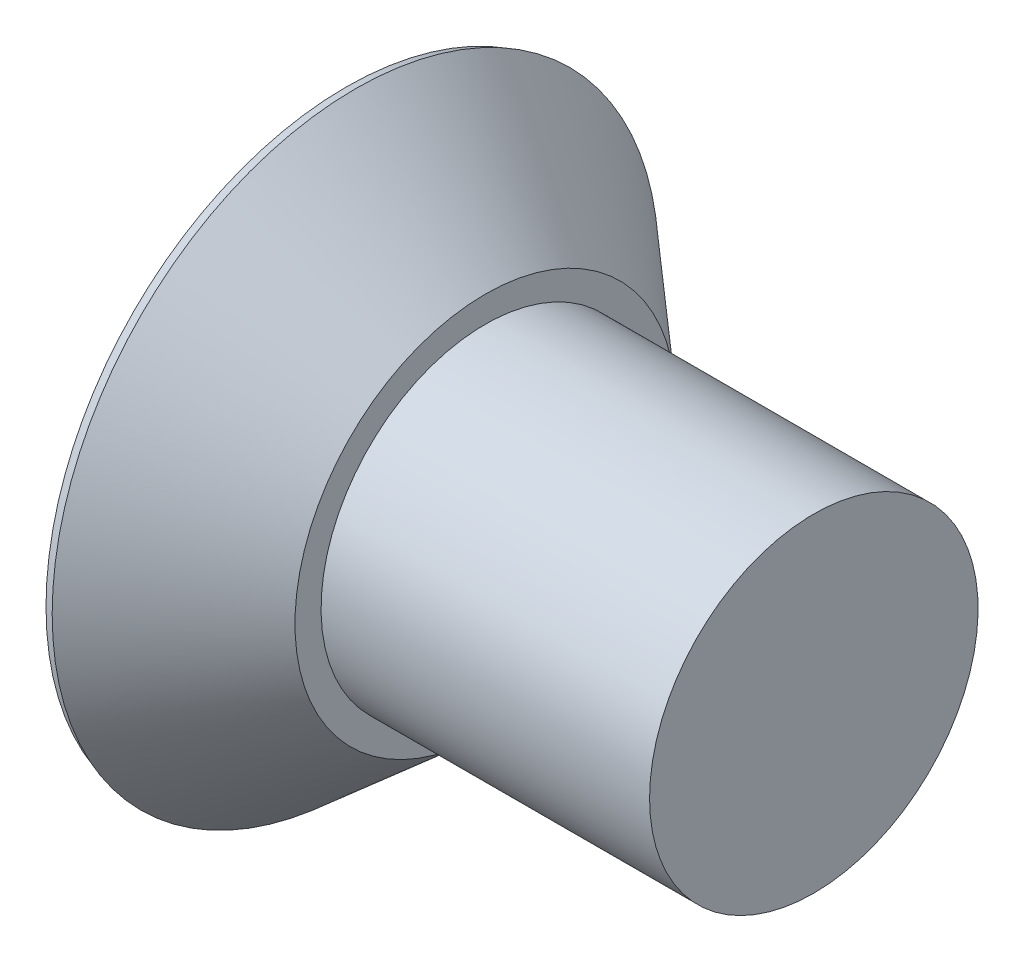
from build123d import *

# Parameters (mm, degrees)
CUT_EXTRUDE1_REACH          = 9.645
CIRPATTERN1_COUNT           = 4
DRAFT1_ANGLE                = 5
CHAMFER1_SIZE               = 0.120396
CHAMFER1_SIZE2              = 0.110273872
SKETCH8_W                   = 2.54
SKETCH8_H                   = 5.08
SCREW_SHORTENING_DEPTH      = 6.221219053
SCREW_SHORTENING_DEPTH_BACK = 6.221219053


with BuildPart() as part:
    # Sketch2 → Revolve1 (revolve)
    with BuildSketch(Plane.XY, mode=Mode.PRIVATE) as revolve1_sk:
        Polygon((-3.175, 0), (3.175, 0), (3.175, 1.5875), (-1.8288, 1.5875), (-1.8288, 1.839666194), (-3.175, 3.0099), align=None)
    revolve(revolve1_sk.sketch.rotate(Axis((-3.175, 0, 0), (1, 0, 0)), 180), axis=Axis((-3.175, 0, 0), (1, 0, 0)))

    # Cut-Extrude1: up to this cone (the profile starts inside it)
    cut_extrude1_end = Plane(origin=(-3.175, 0, 0), z_dir=(-1, 0, 0)).offset(-1.933209747) * Cone(1e-06, 11.960277355, 13.758724211, align=(Align.CENTER, Align.CENTER, Align.MIN), mode=Mode.PRIVATE)
    # Sketch3 → Cut-Extrude1 (cut, up to the surface)
    with BuildSketch(Plane.ZY.offset(3.175), mode=Mode.PRIVATE) as cut_extrude1_sk1:
        with BuildLine():
            Line((0, 0), (2.0066, 0))
            ThreePointArc((2.0066, 0), (1.996438885, 0.201681283), (1.966058447, 0.40132))
            Line((1.966058447, 0.40132), (1.183689224, 0.40132))
            Line((1.183689224, 0.40132), (0.63047064, 0.63047064))
            Line((0.63047064, 0.63047064), (0.40132, 1.183689224))
            Line((0.40132, 1.183689224), (0.40132, 1.966058447))
            ThreePointArc((0.40132, 1.966058447), (0.201681283, 1.996438885), (0, 2.0066))
            Line((0, 2.0066), (0, 0))
        make_face()
    cut_extrude1_tool1 = extrude(cut_extrude1_sk1.sketch, amount=-CUT_EXTRUDE1_REACH, mode=Mode.PRIVATE) & cut_extrude1_end
    cut_extrude1 = cut_extrude1_tool1.solids().sort_by_distance((-3.175, 1.0033, 0.028378))[0]
    add(cut_extrude1, mode=Mode.SUBTRACT)

    # CirPattern1: Cut-Extrude1 ×4 about axis
    cirpattern1_axis = Axis((0, 0, 0), (1, 0, 0))
    for i in range(1, CIRPATTERN1_COUNT):
        add(cut_extrude1.rotate(cirpattern1_axis, i * 360 / CIRPATTERN1_COUNT), mode=Mode.SUBTRACT)

    # Draft1
    draft1_faces = [part.faces().sort_by_distance(p)[0] for p in [
        (-3.009498029, 0.40132, -1.333367825),
        (-2.803736683, 0.526902447, -0.880506376),
        (-2.803736683, 0.880506376, -0.526902447),
        (-3.009498029, 1.333367825, -0.40132),
        (-3.009498029, 1.333367825, 0.40132),
        (-2.803736683, 0.880506376, 0.526902447),
        (-2.803736683, 0.526902447, 0.880506376),
        (-3.009498029, 0.40132, 1.333367825),
        (-3.009498029, -0.40132, 1.333367825),
        (-2.803736683, -0.526902447, 0.880506376),
        (-2.803736683, -0.880506376, 0.526902447),
        (-3.009498029, -1.333367825, 0.40132),
        (-3.009498029, -1.333367825, -0.40132),
        (-2.803736683, -0.880506376, -0.526902447),
        (-2.803736683, -0.526902447, -0.880506376),
        (-3.009498029, -0.40132, -1.333367825),
    ]]
    draft(draft1_faces, Plane(origin=(-3.175, 0, 0), x_dir=(0, -1, 0), z_dir=(-1, 0, 0)), DRAFT1_ANGLE)

    # Chamfer1
    chamfer1_edges = [part.edges().sort_by_distance(p)[0] for p in [
        (-3.175, 3.0099, 0),
    ]]
    chamfer1_side = [part.faces().sort_by_distance(p)[0] for p in [
        (-2.5019, 2.424783097, 0),
    ]]
    chamfer(chamfer1_edges, length=CHAMFER1_SIZE, length2=CHAMFER1_SIZE2, reference=chamfer1_side[0])

    # Sketch8 → Screw Shortening (cut, two sides)
    with BuildSketch(Plane.XY) as screw_shortening_sk:
        with Locations((2.6162, 0)):
            Rectangle(SKETCH8_W, SKETCH8_H)
    extrude(amount=SCREW_SHORTENING_DEPTH, mode=Mode.SUBTRACT)
    extrude(screw_shortening_sk.sketch, amount=-SCREW_SHORTENING_DEPTH_BACK, mode=Mode.SUBTRACT)


solid = part.part
